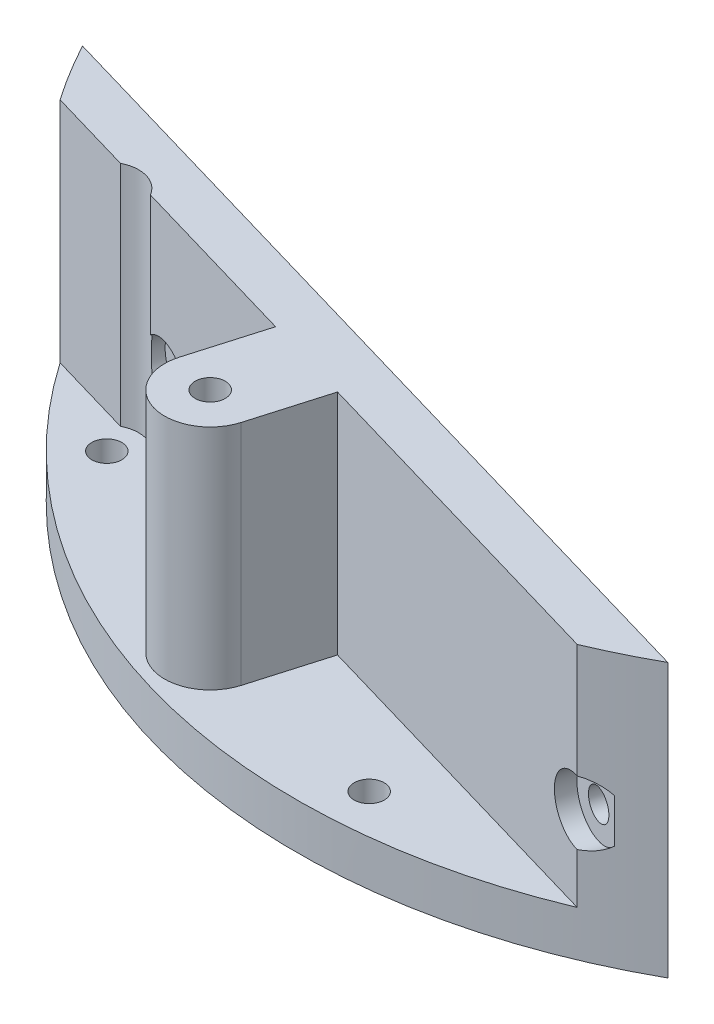
from build123d import *

# Parameters (mm, degrees)
SKETCH1_R           = 1.65
BOSS_EXTRUDE1_DEPTH = 5
BOSS_EXTRUDE2_DEPTH = 25
SKETCH3_R           = 1.65
CUT_EXTRUDE1_DEPTH  = 31.640005718
SKETCH4_R           = 3.5
CUT_EXTRUDE2_DEPTH  = 2
SKETCH5_R           = 67.5
SKETCH5_R_2         = 66.25
CUT_EXTRUDE3_DEPTH  = 31.0000001
SKETCH6_R           = 1.65
BOSS_EXTRUDE3_DEPTH = 30
CUT_EXTRUDE4_START  = -3
CUT_EXTRUDE4_DEPTH  = 2.6


with BuildPart() as part:
    # Sketch1 → Boss-Extrude1 (new body)
    with BuildSketch(Plane(origin=(0, 0, 0), x_dir=(1, 0, 0), z_dir=(0, 1, 0))):
        with BuildLine():
            ThreePointArc((-58.769725256, -31.225340563), (-18.644922026, -63.884813396), (32.748082014, -57.935012077))
            Line((32.748082014, -57.935012077), (-58.769725256, -31.225340563))
        make_face()
        with Locations((-43.522422382, -43.522422382)):
            Circle(SKETCH1_R, mode=Mode.SUBTRACT)
        with Locations((3.221278107, -61.465647864)):
            Circle(SKETCH1_R, mode=Mode.SUBTRACT)
    extrude(amount=BOSS_EXTRUDE1_DEPTH)

    # Sketch2 → Boss-Extrude2 (add)
    with BuildSketch(Plane(origin=(0, 5, 0), x_dir=(1, 0, 0), z_dir=(0, 1, 0))):
        with BuildLine():
            Line((-58.769725256, -31.225340563), (32.748082014, -57.935012077))
            ThreePointArc((32.748082014, -57.935012077), (29.480015366, -59.664320946), (26.120952253, -61.20946294))
            Line((26.120952253, -61.20946294), (-40.494047404, -41.767730103))
            ThreePointArc((-40.494047404, -41.767730103), (-42.54184797, -40.162589972), (-45.131562946, -40.414261085))
            Line((-45.131562946, -40.414261085), (-54.944236671, -37.550410872))
            ThreePointArc((-54.944236671, -37.550410872), (-56.94486731, -34.441030575), (-58.769725256, -31.225340563))
        make_face()
    extrude(amount=BOSS_EXTRUDE2_DEPTH)

    # Sketch3 → Cut-Extrude1 (cut, through all)
    with BuildSketch(Plane(origin=(-14.411642209, 0, 49.379936906), x_dir=(0.959952117, 0, 0.280164118), z_dir=(-0.280164118, 0, 0.959952117))):
        with Locations((41.56355859, 14)):
            Circle(SKETCH3_R)
        with Locations((-24.93644141, 14)):
            Circle(SKETCH3_R)
    extrude(amount=-CUT_EXTRUDE1_DEPTH, mode=Mode.SUBTRACT)

    # Sketch4 → Cut-Extrude2 (cut)
    with BuildSketch(Plane(origin=(-14.411642209, 0, 49.379936906), x_dir=(0.959952117, 0, 0.280164118), z_dir=(-0.280164118, 0, 0.959952117))):
        with Locations((41.56355859, 14)):
            Circle(SKETCH4_R)
        with Locations((-24.93644141, 14)):
            Circle(SKETCH4_R)
    extrude(amount=-CUT_EXTRUDE2_DEPTH, mode=Mode.SUBTRACT)

    # Sketch5 → Cut-Extrude3 (cut, through all)
    with BuildSketch(Plane.XZ):
        Circle(SKETCH5_R)
        Circle(SKETCH5_R_2, mode=Mode.SUBTRACT)
    extrude(amount=-CUT_EXTRUDE3_DEPTH, mode=Mode.SUBTRACT)

    # Sketch6 → Boss-Extrude3 (add)
    with BuildSketch(Plane(origin=(0, 0, 0), x_dir=(1, 0, 0), z_dir=(0, 1, 0))):
        with BuildLine():
            Line((-23.475659958, -55.618568944), (-21.086364171, -47.431904754))
            Line((-21.086364171, -47.431904754), (-11.486842999, -50.23354593))
            Line((-11.486842999, -50.23354593), (-13.876138786, -58.42021012))
            ThreePointArc((-13.876138786, -58.42021012), (-20.07671996, -61.819150118), (-23.475659958, -55.618568944))
        make_face()
        with Locations((-18.675899372, -57.019389532)):
            Circle(SKETCH6_R, mode=Mode.SUBTRACT)
    extrude(amount=BOSS_EXTRUDE3_DEPTH)

    # Sketch7 → Cut-Extrude4 (cut)
    with BuildSketch(Plane(origin=(0, 30, 0), x_dir=(1, 0, 0), z_dir=(0, 1, 0)).offset(CUT_EXTRUDE4_START)):
        Polygon((-15.535775757, -56.547206291), (-17.514760247, -54.06387109), (-20.654883862, -54.536054331), (-21.816022987, -57.491572774), (-19.837038497, -59.974907975), (-16.696914882, -59.502724734), align=None)
    extrude(amount=-CUT_EXTRUDE4_DEPTH, mode=Mode.SUBTRACT)


solid = part.part
